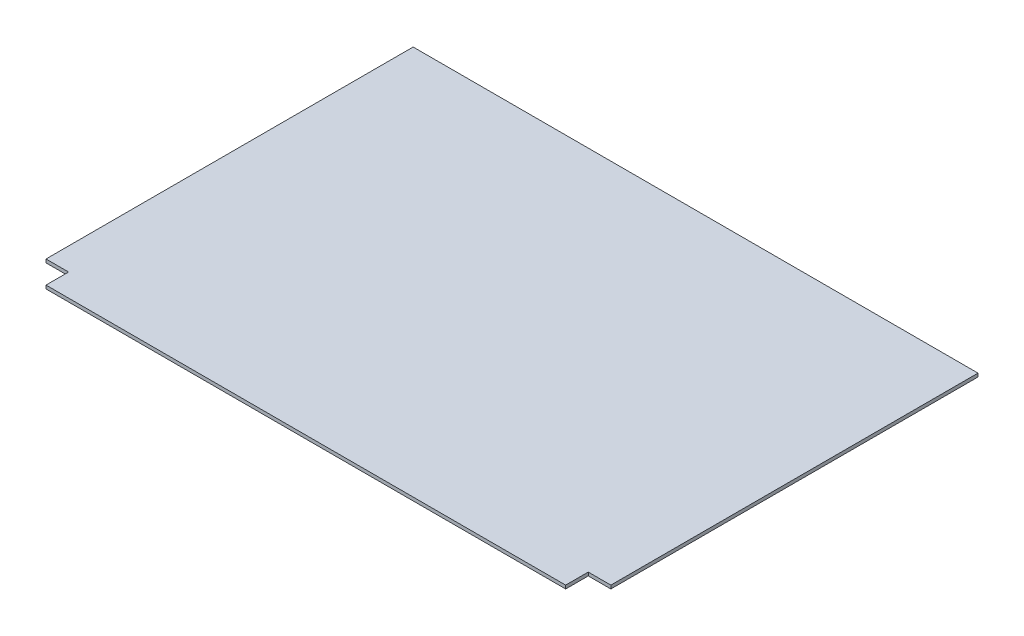
from build123d import *

# Parameters (mm, degrees)
BOSS_EXTRUDE1_DEPTH = 3


with BuildPart() as part:
    # Sketch1 → Boss-Extrude1 (new body)
    with BuildSketch(Plane(origin=(0, 0, 0), x_dir=(1, 0, 0), z_dir=(0, 1, 0))):
        Polygon((250, -155), (230, -155), (230, -175), (-230, -175), (-230, -155), (-250, -155), (-250, 170), (250, 170), align=None)
    extrude(amount=BOSS_EXTRUDE1_DEPTH)


solid = part.part
